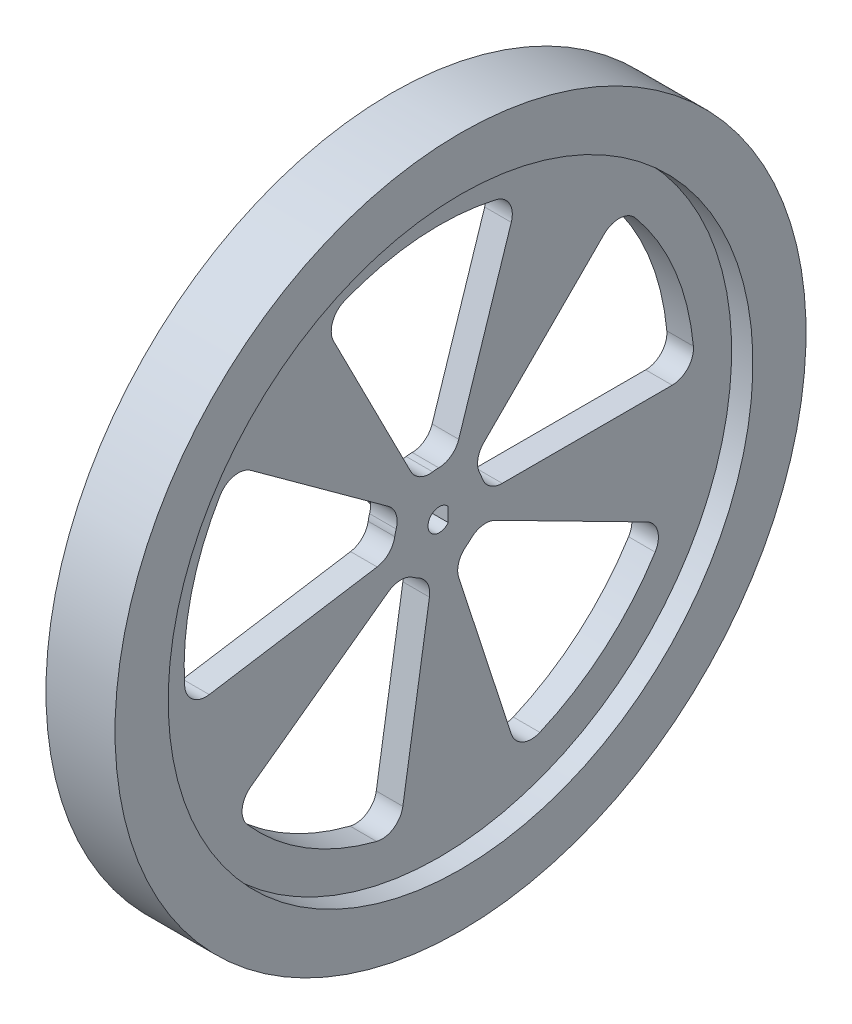
from build123d import *

# Parameters (mm, degrees)
CUT_EXTRUDE1_DEPTH  = 5
CIRPATTERN1_COUNT   = 5
SKETCH8_R           = 2.75
BOSS_EXTRUDE1_DEPTH = 6
CUT_EXTRUDE2_REACH  = 13


with BuildPart() as part:
    # Sketch3 → Shape_Roue (revolve)
    with BuildSketch(Plane.XY):
        Polygon((-2.5, 0), (2.5, 0), (2.5, 55), (6.5, 55), (6.5, 65), (-6.5, 65), (-6.5, 55), (-2.5, 55), align=None)
    revolve(axis=Axis((-2.5, 0, 0), (1, 0, 0)))

    # Sketch6 → Cut-Extrude1 (cut)
    with BuildSketch(Plane(origin=(2.5, 0, 0), x_dir=(0, 0, -1), z_dir=(1, 0, 0))):
        with BuildLine():
            Line((8.374067112, 8.374067112), (30.98386677, 30.98386677))
            ThreePointArc((30.98386677, 30.98386677), (33.994300587, 32.151296695), (36.886138794, 30.715025067))
            ThreePointArc((36.886138794, 30.715025067), (44.346217561, 18.368804754), (47.801241382, 4.363636364))
            ThreePointArc((47.801241382, 4.363636364), (46.772000384, 1.30320055), (43.8178046, 0))
            Line((43.8178046, 0), (11.842719282, 0))
            ThreePointArc((11.842719282, 0), (9.510338524, 0.750384638), (8.053049112, 2.72))
            ThreePointArc((8.053049112, 2.72), (7.852976026, 3.252809175), (7.617696081, 3.771035191))
            ThreePointArc((7.617696081, 3.771035191), (7.255426928, 6.194222796), (8.374067112, 8.374067112))
        make_face()
    cut_extrude1 = extrude(amount=-CUT_EXTRUDE1_DEPTH, mode=Mode.SUBTRACT)

    # CirPattern1: Cut-Extrude1 ×5 about axis
    cirpattern1_axis = Axis((0, 0, 0), (1, 0, 0))
    for i in range(1, CIRPATTERN1_COUNT):
        add(cut_extrude1.rotate(cirpattern1_axis, i * 360 / CIRPATTERN1_COUNT), mode=Mode.SUBTRACT)

    # Sketch8 → Boss-Extrude1 (add)
    with BuildSketch(Plane(origin=(-2.5, 0, 0), x_dir=(0, 0, -1), z_dir=(1, 0, 0))):
        Circle(SKETCH8_R)
    extrude(amount=-BOSS_EXTRUDE1_DEPTH)

    # Sketch7 → Cut-Extrude2 (cut, up to next)
    with BuildSketch(Plane(origin=(2.5, 0, 0), x_dir=(0, 0, -1), z_dir=(1, 0, 0)), mode=Mode.PRIVATE) as cut_extrude2_sk1:
        with BuildLine():
            Line((1.675, 1.307669683), (1.675, -1.307669683))
            ThreePointArc((1.675, -1.307669683), (-2.125, 0), (1.675, 1.307669683))
        make_face()
    cut_extrude2_tool1 = extrude(cut_extrude2_sk1.sketch, amount=-CUT_EXTRUDE2_REACH, mode=Mode.PRIVATE) & part.part
    add(cut_extrude2_tool1.solids().sort_by_distance((2.5, 0, 0.111388))[0], mode=Mode.SUBTRACT)


solid = part.part
